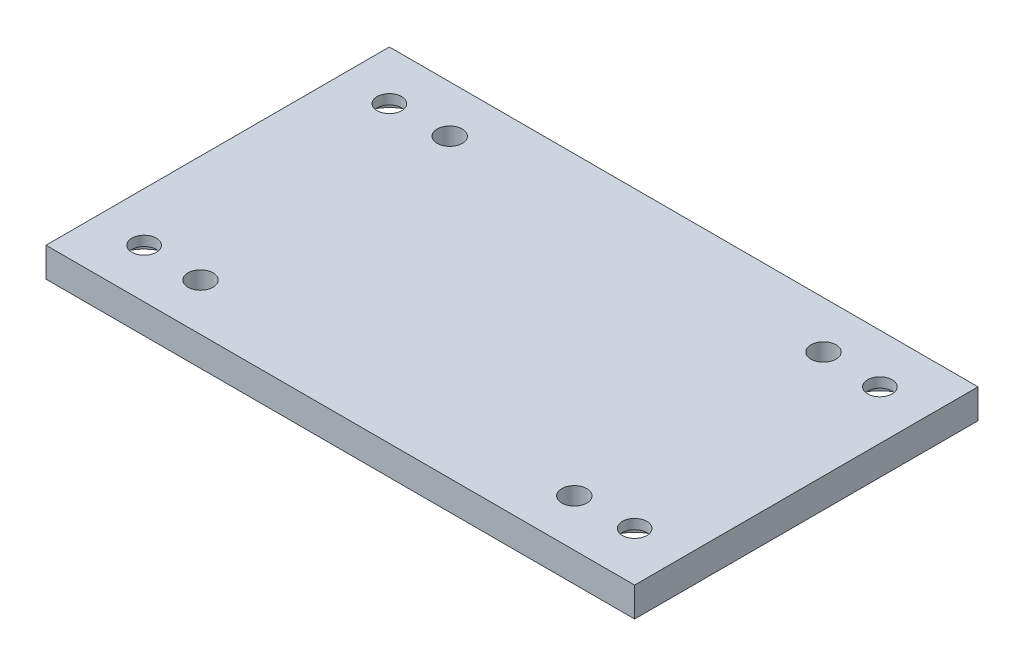
from build123d import *

# Parameters (mm, degrees)
SKETCH1_W           = 120
SKETCH1_H           = 70
SKETCH1_R           = 2.5
BOSS_EXTRUDE1_DEPTH = 6
SKETCH2_R           = 2.555
CUT_EXTRUDE1_DEPTH  = 7
SKETCH3_R           = 7.5
CUT_EXTRUDE2_DEPTH  = 4


with BuildPart() as part:
    # Sketch1 → Boss-Extrude1 (new body)
    with BuildSketch(Plane(origin=(0, 0, 0), x_dir=(1, 0, 0), z_dir=(0, 1, 0))):
        Rectangle(SKETCH1_W, SKETCH1_H)
        with Locations((-50, -25)):
            Circle(SKETCH1_R, mode=Mode.SUBTRACT)
        with Locations((-50, 25)):
            Circle(SKETCH1_R, mode=Mode.SUBTRACT)
        with Locations((50, 25)):
            Circle(SKETCH1_R, mode=Mode.SUBTRACT)
        with Locations((50, -25)):
            Circle(SKETCH1_R, mode=Mode.SUBTRACT)
    extrude(amount=BOSS_EXTRUDE1_DEPTH)

    # Sketch2 → Cut-Extrude1 (cut, through all)
    with BuildSketch(Plane(origin=(0, 6, 0), x_dir=(1, 0, 0), z_dir=(0, 1, 0))):
        with Locations((38.1, -25.4)):
            Circle(SKETCH2_R)
        with Locations((-38.1, -25.4)):
            Circle(SKETCH2_R)
        with Locations((38.1, 25.4)):
            Circle(SKETCH2_R)
        with Locations((-38.1, 25.4)):
            Circle(SKETCH2_R)
    extrude(amount=-CUT_EXTRUDE1_DEPTH, mode=Mode.SUBTRACT)

    # Sketch3 → Cut-Extrude2 (cut)
    with BuildSketch(Plane(origin=(0, 0, 0), x_dir=(1, 0, 0), z_dir=(0, 1, 0))):
        with Locations((-50, 25)):
            Circle(SKETCH3_R)
        with Locations((50, 25)):
            Circle(SKETCH3_R)
        with Locations((50, -25)):
            Circle(SKETCH3_R)
        with Locations((-50, -25)):
            Circle(SKETCH3_R)
    extrude(amount=CUT_EXTRUDE2_DEPTH, mode=Mode.SUBTRACT)


solid = part.part
